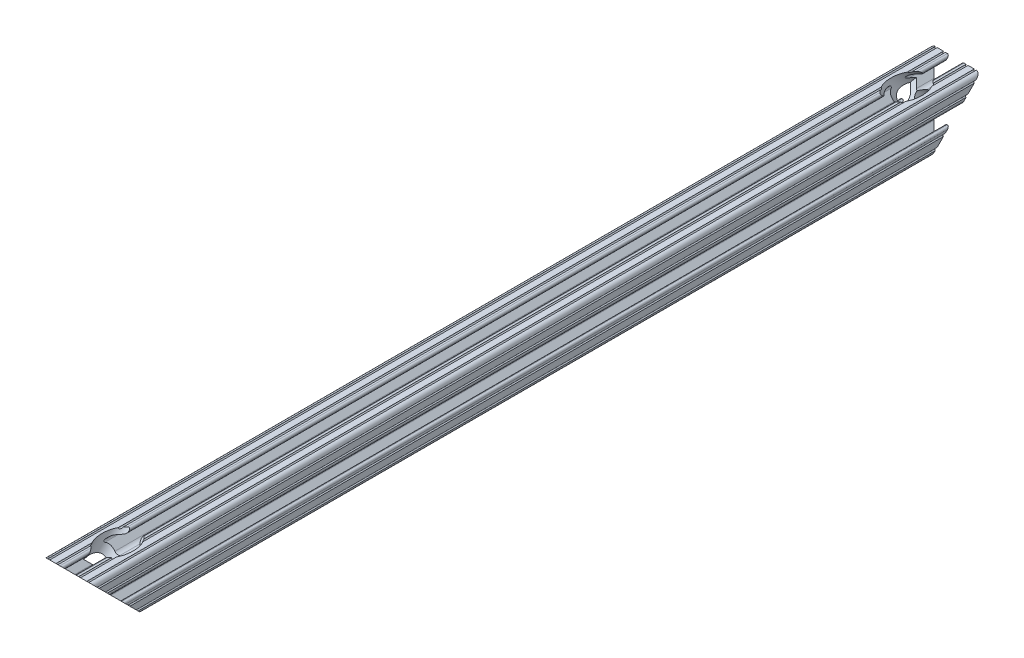
from build123d import *

# Parameters (mm, degrees)
SKETCH1_R               = 2.6035
BOSS_EXTRUDE1_DEPTH     = 228.6
CUT_EXTRUDE1_DEPTH      = 230.304470083
CUT_EXTRUDE1_DEPTH_BACK = 230.304470083
CUT_REVOLVE1_ANGLE      = 360


with BuildPart() as part:
    # Sketch1 → Boss-Extrude1 (new, symmetric)
    with BuildSketch(Plane.XY):
        with BuildLine():
            Line((-7.179650497, -8.645192506), (-3.952270251, -5.423690499))
            ThreePointArc((-3.952270251, -5.423690499), (-2.922936451, -4.736929036), (-1.709253557, -4.4958))
            Line((-1.709253557, -4.4958), (1.709253557, -4.4958))
            ThreePointArc((1.709253557, -4.4958), (2.922936451, -4.736929036), (3.952270251, -5.423690499))
            Line((3.952270251, -5.423690499), (7.179650497, -8.645192506))
            ThreePointArc((7.179650497, -8.645192506), (7.41473083, -9.822813117), (6.416408329, -10.4902))
            Line((6.416408329, -10.4902), (4.287512407, -10.4902))
            ThreePointArc((4.287512407, -10.4902), (3.54574862, -10.79744862), (3.2385, -11.539212407))
            Line((3.2385, -11.539212407), (3.2385, -11.650987593))
            ThreePointArc((3.2385, -11.650987593), (3.54574862, -12.39275138), (4.287512407, -12.7))
            Line((4.287512407, -12.7), (5.317126718, -12.7))
            ThreePointArc((5.317126718, -12.7), (5.825126718, -12.192), (6.333126718, -12.7))
            Line((6.333126718, -12.7), (9.550443118, -12.7))
            ThreePointArc((9.550443118, -12.7), (10.058366869, -12.192000006), (10.566443095, -12.699847501))
            ThreePointArc((10.566443095, -12.699847501), (12.082537762, -12.08250727), (12.699846982, -10.566399977))
            ThreePointArc((12.699846982, -10.566399977), (12.192000006, -10.058323491), (12.7, -9.5504))
            Line((12.7, -9.5504), (12.7, -6.3330836))
            ThreePointArc((12.7, -6.3330836), (12.192, -5.8250836), (12.7, -5.3170836))
            Line((12.7, -5.3170836), (12.7, -4.287469289))
            ThreePointArc((12.7, -4.287469289), (12.39275138, -3.545705502), (11.650987593, -3.238456882))
            Line((11.650987593, -3.238456882), (11.539212407, -3.238456882))
            ThreePointArc((11.539212407, -3.238456882), (10.79744862, -3.545705502), (10.4902, -4.287469289))
            Line((10.4902, -4.287469289), (10.4902, -6.402089023))
            ThreePointArc((10.4902, -6.402089023), (9.856505071, -7.351067942), (8.737131347, -7.129408934))
            Line((8.737131347, -7.129408934), (5.441005833, -3.840816462))
            ThreePointArc((5.441005833, -3.840816462), (4.750877967, -2.809883091), (4.5085, -1.593185507))
            Line((4.5085, -1.593185507), (4.5085, 1.593185507))
            ThreePointArc((4.5085, 1.593185507), (4.750877967, 2.809883091), (5.441005833, 3.840816462))
            Line((5.441005833, 3.840816462), (8.737131347, 7.129408934))
            ThreePointArc((8.737131347, 7.129408934), (9.856505071, 7.351067942), (10.4902, 6.402089023))
            Line((10.4902, 6.402089023), (10.4902, 4.287469289))
            ThreePointArc((10.4902, 4.287469289), (10.79744862, 3.545705502), (11.539212407, 3.238456882))
            Line((11.539212407, 3.238456882), (11.650987593, 3.238456882))
            ThreePointArc((11.650987593, 3.238456882), (12.39275138, 3.545705502), (12.7, 4.287469289))
            Line((12.7, 4.287469289), (12.7, 5.3170836))
            ThreePointArc((12.7, 5.3170836), (12.192, 5.8250836), (12.7, 6.3330836))
            Line((12.7, 6.3330836), (12.7, 9.5504))
            ThreePointArc((12.7, 9.5504), (12.192000006, 10.058323491), (12.699846982, 10.566399977))
            ThreePointArc((12.699846982, 10.566399977), (12.082537762, 12.08250727), (10.566443095, 12.699847501))
            ThreePointArc((10.566443095, 12.699847501), (10.058366869, 12.192000006), (9.550443118, 12.7))
            Line((9.550443118, 12.7), (6.333126718, 12.7))
            ThreePointArc((6.333126718, 12.7), (5.825126718, 12.192), (5.317126718, 12.7))
            Line((5.317126718, 12.7), (4.287512407, 12.7))
            ThreePointArc((4.287512407, 12.7), (3.54574862, 12.39275138), (3.2385, 11.650987593))
            Line((3.2385, 11.650987593), (3.2385, 11.539212407))
            ThreePointArc((3.2385, 11.539212407), (3.54574862, 10.79744862), (4.287512407, 10.4902))
            Line((4.287512407, 10.4902), (6.476788598, 10.4902))
            ThreePointArc((6.476788598, 10.4902), (7.432222385, 9.85140422), (7.207036008, 8.724370562))
            Line((7.207036008, 8.724370562), (3.898272566, 5.423169045))
            ThreePointArc((3.898272566, 5.423169045), (2.869120213, 4.736787962), (1.655778399, 4.4958))
            Line((1.655778399, 4.4958), (-1.655778399, 4.4958))
            ThreePointArc((-1.655778399, 4.4958), (-2.869120213, 4.736787962), (-3.898272566, 5.423169045))
            Line((-3.898272566, 5.423169045), (-7.207036008, 8.724370562))
            ThreePointArc((-7.207036008, 8.724370562), (-7.432222385, 9.85140422), (-6.476788598, 10.4902))
            Line((-6.476788598, 10.4902), (-4.287512407, 10.4902))
            ThreePointArc((-4.287512407, 10.4902), (-3.54574862, 10.79744862), (-3.2385, 11.539212407))
            Line((-3.2385, 11.539212407), (-3.2385, 11.650987593))
            ThreePointArc((-3.2385, 11.650987593), (-3.54574862, 12.39275138), (-4.287512407, 12.7))
            Line((-4.287512407, 12.7), (-5.317126718, 12.7))
            ThreePointArc((-5.317126718, 12.7), (-5.825126718, 12.192), (-6.333126718, 12.7))
            Line((-6.333126718, 12.7), (-9.550443118, 12.7))
            ThreePointArc((-9.550443118, 12.7), (-10.058366869, 12.192000006), (-10.566443095, 12.699847501))
            ThreePointArc((-10.566443095, 12.699847501), (-12.082537762, 12.08250727), (-12.699846982, 10.566399977))
            ThreePointArc((-12.699846982, 10.566399977), (-12.192000006, 10.058323491), (-12.7, 9.5504))
            Line((-12.7, 9.5504), (-12.7, 6.3330836))
            ThreePointArc((-12.7, 6.3330836), (-12.192, 5.8250836), (-12.7, 5.3170836))
            Line((-12.7, 5.3170836), (-12.7, 4.287469289))
            ThreePointArc((-12.7, 4.287469289), (-12.39275138, 3.545705502), (-11.650987593, 3.238456882))
            Line((-11.650987593, 3.238456882), (-11.539212407, 3.238456882))
            ThreePointArc((-11.539212407, 3.238456882), (-10.79744862, 3.545705502), (-10.4902, 4.287469289))
            Line((-10.4902, 4.287469289), (-10.4902, 6.402089023))
            ThreePointArc((-10.4902, 6.402089023), (-9.856505071, 7.351067942), (-8.737131347, 7.129408934))
            Line((-8.737131347, 7.129408934), (-5.441005833, 3.840816462))
            ThreePointArc((-5.441005833, 3.840816462), (-4.750877967, 2.809883091), (-4.5085, 1.593185507))
            Line((-4.5085, 1.593185507), (-4.5085, -1.593185507))
            ThreePointArc((-4.5085, -1.593185507), (-4.750877967, -2.809883091), (-5.441005833, -3.840816462))
            Line((-5.441005833, -3.840816462), (-8.737131347, -7.129408934))
            ThreePointArc((-8.737131347, -7.129408934), (-9.856505071, -7.351067942), (-10.4902, -6.402089023))
            Line((-10.4902, -6.402089023), (-10.4902, -4.287469289))
            ThreePointArc((-10.4902, -4.287469289), (-10.79744862, -3.545705502), (-11.539212407, -3.238456882))
            Line((-11.539212407, -3.238456882), (-11.650987593, -3.238456882))
            ThreePointArc((-11.650987593, -3.238456882), (-12.39275138, -3.545705502), (-12.7, -4.287469289))
            Line((-12.7, -4.287469289), (-12.7, -5.3170836))
            ThreePointArc((-12.7, -5.3170836), (-12.192, -5.8250836), (-12.7, -6.3330836))
            Line((-12.7, -6.3330836), (-12.7, -9.5504))
            ThreePointArc((-12.7, -9.5504), (-12.192000006, -10.058323491), (-12.699846982, -10.566399977))
            ThreePointArc((-12.699846982, -10.566399977), (-12.082537762, -12.08250727), (-10.566443095, -12.699847501))
            ThreePointArc((-10.566443095, -12.699847501), (-10.058366869, -12.192000006), (-9.550443118, -12.7))
            Line((-9.550443118, -12.7), (-6.333126718, -12.7))
            ThreePointArc((-6.333126718, -12.7), (-5.825126718, -12.192), (-5.317126718, -12.7))
            Line((-5.317126718, -12.7), (-4.287512407, -12.7))
            ThreePointArc((-4.287512407, -12.7), (-3.54574862, -12.39275138), (-3.2385, -11.650987593))
            Line((-3.2385, -11.650987593), (-3.2385, -11.539212407))
            ThreePointArc((-3.2385, -11.539212407), (-3.54574862, -10.79744862), (-4.287512407, -10.4902))
            Line((-4.287512407, -10.4902), (-6.416408329, -10.4902))
            ThreePointArc((-6.416408329, -10.4902), (-7.41473083, -9.822813117), (-7.179650497, -8.645192506))
        make_face()
        Circle(SKETCH1_R, mode=Mode.SUBTRACT)
    extrude(amount=BOSS_EXTRUDE1_DEPTH, both=True)

    # Sketch2 → Cut-Extrude1 (cut, two sides)
    with BuildSketch(Plane(origin=(0, 0, 0), x_dir=(0, 0, -1), z_dir=(1, 0, 0))) as cut_extrude1_sk:
        Polygon((-228.6, 12.699847501), (-228.6, -12.7), (-203.200152499, -12.7), align=None)
        Polygon((203.200152499, -12.7), (228.6, 12.699847501), (228.6, -12.7), align=None)
    extrude(amount=CUT_EXTRUDE1_DEPTH, mode=Mode.SUBTRACT)
    extrude(cut_extrude1_sk.sketch, amount=-CUT_EXTRUDE1_DEPTH_BACK, mode=Mode.SUBTRACT)

    # Sketch3 → Cut-Revolve1 (revolve, symmetric, cut)
    with BuildSketch(Plane(origin=(0, 0, 0), x_dir=(0, 0, -1), z_dir=(1, 0, 0))) as cut_revolve1_sk:
        Polygon((-197.587644922, 18.312507577), (-215.900152499, 0), (-218.208078322, 2.307925823), (-213.717950261, 6.798053884), (-217.022684514, 10.102788136), (-203.200304998, 23.925167653), align=None)
    cut_revolve1 = revolve(axis=Axis((0, 0, 215.900152499), (0, -0.7071067811865471, 0.7071067811865479)), revolution_arc=CUT_REVOLVE1_ANGLE / 2, mode=Mode.SUBTRACT)
    cut_revolve1 = cut_revolve1 + revolve(cut_revolve1_sk.sketch, axis=Axis((0, 0, 215.900152499), (0, 0.7071067811865471, -0.7071067811865479)), revolution_arc=CUT_REVOLVE1_ANGLE / 2, mode=Mode.SUBTRACT)

    # Mirror1: Cut-Revolve1 across plane
    add(cut_revolve1.mirror(Plane.XY), mode=Mode.SUBTRACT)


solid = part.part
